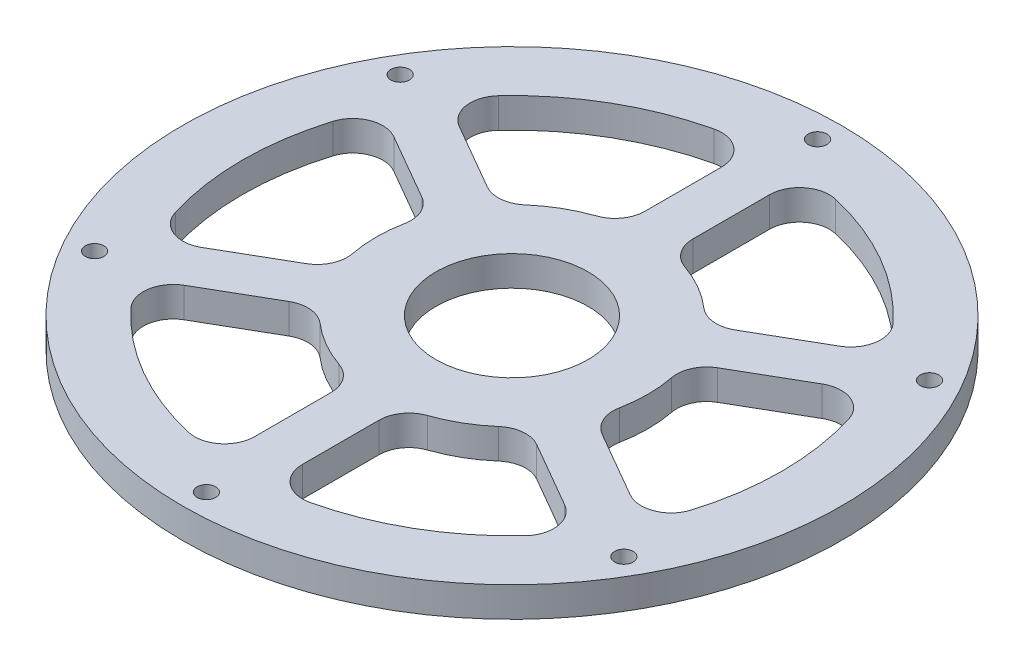
from build123d import *

# Parameters (mm, degrees)
SKETCH1_R           = 55
BOSS_EXTRUDE1_DEPTH = 5
SKETCH2_R           = 1.55
CUT_EXTRUDE1_DEPTH  = 6
SKETCH5_R           = 12.7
CUT_EXTRUDE4_DEPTH  = 6
CUT_EXTRUDE5_DEPTH  = 6
FILLET1_R           = 5
FILLET2_R           = 5
SKETCH8_R           = 3.25
CUT_EXTRUDE6_DEPTH  = 2.5
CIRPATTERN3_COUNT   = 6


with BuildPart() as part:
    # Sketch1 → Boss-Extrude1 (new body)
    with BuildSketch(Plane(origin=(0, 0, 0), x_dir=(1, 0, 0), z_dir=(0, 1, 0))):
        Circle(SKETCH1_R)
    extrude(amount=BOSS_EXTRUDE1_DEPTH)

    # Sketch2 → Cut-Extrude1 (cut, through all)
    with BuildSketch(Plane(origin=(0, 5, 0), x_dir=(1, 0, 0), z_dir=(0, 1, 0))):
        with Locations((0, 51)):
            Circle(SKETCH2_R)
        with Locations((44.167295593, 25.5)):
            Circle(SKETCH2_R)
        with Locations((44.167295593, -25.5)):
            Circle(SKETCH2_R)
        with Locations((0, -51)):
            Circle(SKETCH2_R)
        with Locations((-44.167295593, -25.5)):
            Circle(SKETCH2_R)
        with Locations((-44.167295593, 25.5)):
            Circle(SKETCH2_R)
    extrude(amount=-CUT_EXTRUDE1_DEPTH, mode=Mode.SUBTRACT)

    # Sketch5 → Cut-Extrude4 (cut, through all)
    with BuildSketch(Plane(origin=(0, 5, 0), x_dir=(1, 0, 0), z_dir=(0, 1, 0))):
        Circle(SKETCH5_R)
    extrude(amount=-CUT_EXTRUDE4_DEPTH, mode=Mode.SUBTRACT)

    # Sketch7 → Cut-Extrude5 (cut, through all)
    with BuildSketch(Plane(origin=(0, 5, 0), x_dir=(1, 0, 0), z_dir=(0, 1, 0))):
        with BuildLine():
            Line((-21.351162756, 7.708297411), (-40.816877772, 18.946833216))
            ThreePointArc((-40.816877772, 18.946833216), (-45, 0), (-40.816877772, -18.946833216))
            Line((-40.816877772, -18.946833216), (-21.351162756, -7.708297411))
            ThreePointArc((-21.351162756, -7.708297411), (-22.7, 0), (-21.351162756, 7.708297411))
        make_face()
        with BuildLine():
            Line((-17.351162756, -14.636500641), (-36.816877772, -25.875036446))
            ThreePointArc((-36.816877772, -25.875036446), (-22.5, -38.97114317), (-4, -44.821869662))
            Line((-4, -44.821869662), (-4, -22.344798052))
            ThreePointArc((-4, -22.344798052), (-11.35, -19.658776666), (-17.351162756, -14.636500641))
        make_face()
        with BuildLine():
            ThreePointArc((4, -44.821869662), (22.5, -38.97114317), (36.816877772, -25.875036446))
            Line((36.816877772, -25.875036446), (17.351162756, -14.636500641))
            ThreePointArc((17.351162756, -14.636500641), (11.35, -19.658776666), (4, -22.344798052))
            Line((4, -22.344798052), (4, -44.821869662))
        make_face()
        with BuildLine():
            ThreePointArc((45, 0), (43.941776818, 9.701559159), (40.816877772, 18.946833216))
            Line((40.816877772, 18.946833216), (21.351162756, 7.708297411))
            ThreePointArc((21.351162756, 7.708297411), (22.360248149, 3.912710406), (22.7, 0))
            ThreePointArc((22.7, 0), (22.360248149, -3.912710406), (21.351162756, -7.708297411))
            Line((21.351162756, -7.708297411), (40.816877772, -18.946833216))
            ThreePointArc((40.816877772, -18.946833216), (43.941776818, -9.701559159), (45, 0))
        make_face()
        with BuildLine():
            ThreePointArc((36.816877772, 25.875036446), (22.5, 38.97114317), (4, 44.821869662))
            Line((4, 44.821869662), (4, 22.344798052))
            ThreePointArc((4, 22.344798052), (11.35, 19.658776666), (17.351162756, 14.636500641))
            Line((17.351162756, 14.636500641), (36.816877772, 25.875036446))
        make_face()
        with BuildLine():
            Line((-4, 22.344798052), (-4, 44.821869662))
            ThreePointArc((-4, 44.821869662), (-22.5, 38.97114317), (-36.816877772, 25.875036446))
            Line((-36.816877772, 25.875036446), (-17.351162756, 14.636500641))
            ThreePointArc((-17.351162756, 14.636500641), (-11.35, 19.658776666), (-4, 22.344798052))
        make_face()
    extrude(amount=-CUT_EXTRUDE5_DEPTH, mode=Mode.SUBTRACT)

    # Fillet1
    fillet1_edges = [part.edges().sort_by_distance(p)[0] for p in [
        (-40.816877772, 2.5, -18.946833216),
        (-21.351162756, 2.5, -7.708297411),
        (-21.351162756, 2.5, 7.708297411),
        (-40.816877772, 2.5, 18.946833216),
    ]]
    fillet(fillet1_edges, radius=FILLET1_R)

    # Fillet2
    fillet2_edges = [part.edges().sort_by_distance(p)[0] for p in [
        (40.816877772, 2.5, 18.946833216),
        (21.351162756, 2.5, 7.708297411),
        (21.351162756, 2.5, -7.708297411),
        (40.816877772, 2.5, -18.946833216),
        (36.816877772, 2.5, -25.875036446),
        (17.351162756, 2.5, -14.636500641),
        (4, 2.5, -22.344798052),
        (4, 2.5, -44.821869662),
        (4, 2.5, 44.821869662),
        (4, 2.5, 22.344798052),
        (17.351162756, 2.5, 14.636500641),
        (36.816877772, 2.5, 25.875036446),
        (-36.816877772, 2.5, 25.875036446),
        (-17.351162756, 2.5, 14.636500641),
        (-4, 2.5, 22.344798052),
        (-4, 2.5, 44.821869662),
        (-4, 2.5, -44.821869662),
        (-4, 2.5, -22.344798052),
        (-17.351162756, 2.5, -14.636500641),
        (-36.816877772, 2.5, -25.875036446),
    ]]
    fillet(fillet2_edges, radius=FILLET2_R)

    # Sketch8 → Cut-Extrude6 (cut)
    with BuildSketch(Plane(origin=(0, 0, 0), x_dir=(1, 0, 0), z_dir=(0, 1, 0))):
        with Locations((0, 51)):
            Circle(SKETCH8_R)
    cut_extrude6 = extrude(amount=CUT_EXTRUDE6_DEPTH, mode=Mode.SUBTRACT)

    # CirPattern3: Cut-Extrude6 ×6 about axis
    cirpattern3_axis = Axis((0, 0, 0), (0, 1, 0))
    for i in range(1, CIRPATTERN3_COUNT):
        add(cut_extrude6.rotate(cirpattern3_axis, i * 360 / CIRPATTERN3_COUNT), mode=Mode.SUBTRACT)


solid = part.part
